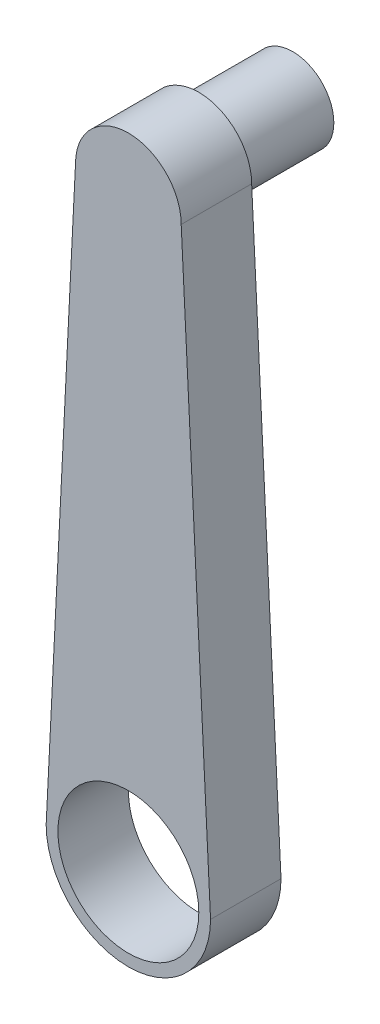
from build123d import *

# Parameters (mm, degrees)
EXTRUDE_1_DEPTH     = 60
SKETCH_2_R          = 60
CUT_EXTRUDE_1_DEPTH = 60
SKETCH_3_R          = 35
EXTRUDE_2_DEPTH     = 80


with BuildPart() as part:
    # Эскиз1 → Бобышка-Вытянуть1 (new body)
    with BuildSketch(Plane.XY):
        with BuildLine():
            Line((-69.650872818, 6.982543641), (-70, 0))
            ThreePointArc((-70, 0), (0, -70), (70, 0))
            Line((70, 0), (69.650872818, 6.982543641))
            Line((69.650872818, 6.982543641), (45, 500))
            ThreePointArc((45, 500), (0, 545), (-45, 500))
            Line((-45, 500), (-69.650872818, 6.982543641))
        make_face()
    extrude(amount=EXTRUDE_1_DEPTH)

    # Эскиз2 → Вырез-Вытянуть1 (cut)
    with BuildSketch(Plane.XY.offset(60)):
        Circle(SKETCH_2_R)
    extrude(amount=-CUT_EXTRUDE_1_DEPTH, mode=Mode.SUBTRACT)

    # Эскиз3 → Бобышка-Вытянуть2 (add)
    with BuildSketch(Plane(origin=(0, 0, 0), x_dir=(-1, 0, 0), z_dir=(0, 0, -1))):
        with Locations((0, 500)):
            Circle(SKETCH_3_R)
    extrude(amount=EXTRUDE_2_DEPTH)


solid = part.part
